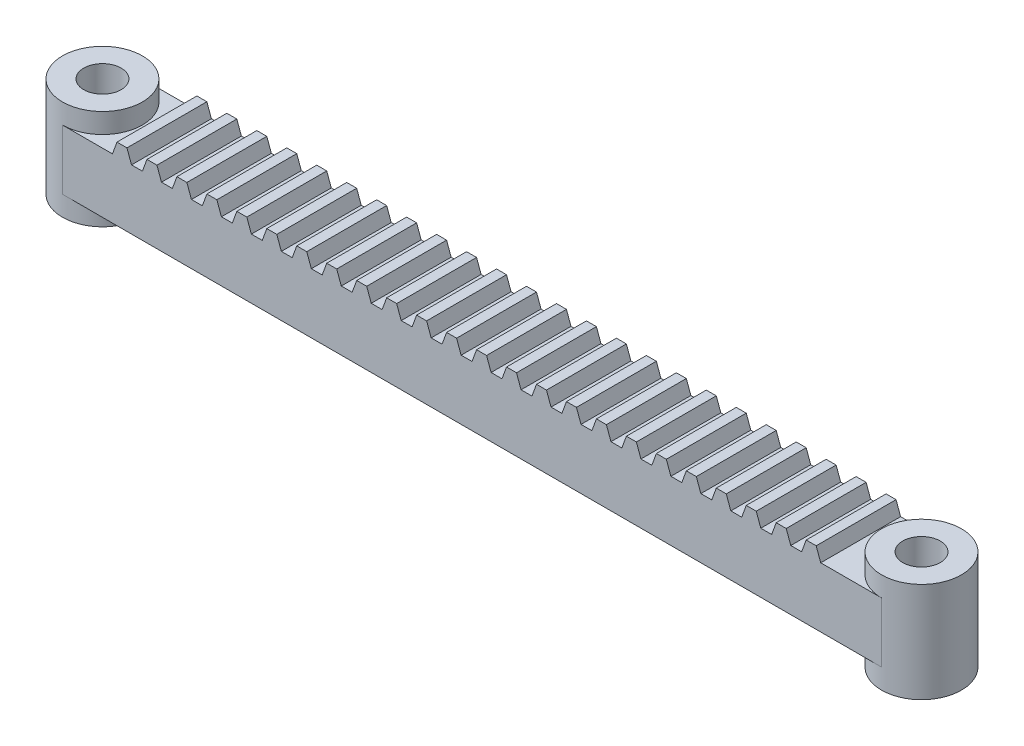
from build123d import *

# Parameters (mm, degrees)
SKETCH1_R                = 3.75
BOSS_EXTRUDE1_DEPTH      = 12
SKETCH1_3_R              = 3.75
BOSS_EXTRUDE2_DEPTH      = 16
BOSS_EXTRUDE2_DEPTH_BACK = 4
BOSS_EXTRUDE3_DEPTH      = 16


with BuildPart() as part:
    # Sketch1 → Boss-Extrude1 (new body)
    with BuildSketch(Plane(origin=(0, 0, 0), x_dir=(1, 0, 0), z_dir=(0, 1, 0))):
        with BuildLine():
            Line((82, 8), (-82, 8))
            ThreePointArc((-82, 8), (-76.343145751, 5.656854249), (-74, 0))
            ThreePointArc((-74, 0), (-76.343145751, -5.656854249), (-82, -8))
            Line((-82, -8), (82, -8))
            ThreePointArc((82, -8), (74, 0), (82, 8))
        make_face()
        with BuildLine():
            ThreePointArc((-74, 0), (-76.343145751, 5.656854249), (-82, 8))
            ThreePointArc((-82, 8), (-90, 0), (-82, -8))
            ThreePointArc((-82, -8), (-76.343145751, -5.656854249), (-74, 0))
        make_face()
        with Locations((-82, 0)):
            Circle(SKETCH1_R, mode=Mode.SUBTRACT)
        with BuildLine():
            ThreePointArc((90, 0), (87.656854249, 5.656854249), (82, 8))
            ThreePointArc((82, 8), (74, 0), (82, -8))
            ThreePointArc((82, -8), (87.656854249, -5.656854249), (90, 0))
        make_face()
        with Locations((82, 0)):
            Circle(SKETCH1_R, mode=Mode.SUBTRACT)
    extrude(amount=BOSS_EXTRUDE1_DEPTH)

    # Sketch1_3 → Boss-Extrude2 (add, two sides)
    with BuildSketch(Plane(origin=(0, 0, 0), x_dir=(1, 0, 0), z_dir=(0, 1, 0))) as boss_extrude2_sk:
        with BuildLine():
            ThreePointArc((-74, 0), (-76.343145751, 5.656854249), (-82, 8))
            ThreePointArc((-82, 8), (-90, 0), (-82, -8))
            ThreePointArc((-82, -8), (-76.343145751, -5.656854249), (-74, 0))
        make_face()
        with Locations((-82, 0)):
            Circle(SKETCH1_3_R, mode=Mode.SUBTRACT)
        with BuildLine():
            ThreePointArc((90, 0), (87.656854249, 5.656854249), (82, 8))
            ThreePointArc((82, 8), (74, 0), (82, -8))
            ThreePointArc((82, -8), (87.656854249, -5.656854249), (90, 0))
        make_face()
        with Locations((82, 0)):
            Circle(SKETCH1_3_R, mode=Mode.SUBTRACT)
    extrude(amount=BOSS_EXTRUDE2_DEPTH)
    extrude(boss_extrude2_sk.sketch, amount=-BOSS_EXTRUDE2_DEPTH_BACK)

    # Sketch2 → Boss-Extrude3 (add)
    with BuildSketch(Plane.XY.offset(8)):
        Polygon((-72, 12), (-71.090074414, 14.5), (-69.090074414, 14.5), (-68.180148829, 12), align=None)
        Polygon((-62.180148829, 12), (-66, 12), (-65.090074414, 14.5), (-63.090074414, 14.5), align=None)
        Polygon((-56.180148829, 12), (-60, 12), (-59.090074414, 14.5), (-57.090074414, 14.5), align=None)
        Polygon((-50.180148829, 12), (-54, 12), (-53.090074414, 14.5), (-51.090074414, 14.5), align=None)
        Polygon((-44.180148829, 12), (-48, 12), (-47.090074414, 14.5), (-45.090074414, 14.5), align=None)
        Polygon((-38.180148829, 12), (-42, 12), (-41.090074414, 14.5), (-39.090074414, 14.5), align=None)
        Polygon((-32.180148829, 12), (-36, 12), (-35.090074414, 14.5), (-33.090074414, 14.5), align=None)
        Polygon((-26.180148829, 12), (-30, 12), (-29.090074414, 14.5), (-27.090074414, 14.5), align=None)
        Polygon((-20.180148829, 12), (-24, 12), (-23.090074414, 14.5), (-21.090074414, 14.5), align=None)
        Polygon((-14.180148829, 12), (-18, 12), (-17.090074414, 14.5), (-15.090074414, 14.5), align=None)
        Polygon((-8.180148829, 12), (-12, 12), (-11.090074414, 14.5), (-9.090074414, 14.5), align=None)
        Polygon((-2.180148829, 12), (-6, 12), (-5.090074414, 14.5), (-3.090074414, 14.5), align=None)
        Polygon((3.819851171, 12), (0, 12), (0.909925586, 14.5), (2.909925586, 14.5), align=None)
        Polygon((9.819851171, 12), (6, 12), (6.909925586, 14.5), (8.909925586, 14.5), align=None)
        Polygon((15.819851171, 12), (12, 12), (12.909925586, 14.5), (14.909925586, 14.5), align=None)
        Polygon((21.819851171, 12), (18, 12), (18.909925586, 14.5), (20.909925586, 14.5), align=None)
        Polygon((27.819851171, 12), (24, 12), (24.909925586, 14.5), (26.909925586, 14.5), align=None)
        Polygon((33.819851171, 12), (30, 12), (30.909925586, 14.5), (32.909925586, 14.5), align=None)
        Polygon((39.819851171, 12), (36, 12), (36.909925586, 14.5), (38.909925586, 14.5), align=None)
        Polygon((45.819851171, 12), (42, 12), (42.909925586, 14.5), (44.909925586, 14.5), align=None)
        Polygon((51.819851171, 12), (48, 12), (48.909925586, 14.5), (50.909925586, 14.5), align=None)
        Polygon((57.819851171, 12), (54, 12), (54.909925586, 14.5), (56.909925586, 14.5), align=None)
        Polygon((63.819851171, 12), (60, 12), (60.909925586, 14.5), (62.909925586, 14.5), align=None)
        Polygon((69.819851171, 12), (66, 12), (66.909925586, 14.5), (68.909925586, 14.5), align=None)
    extrude(amount=-BOSS_EXTRUDE3_DEPTH)


solid = part.part
